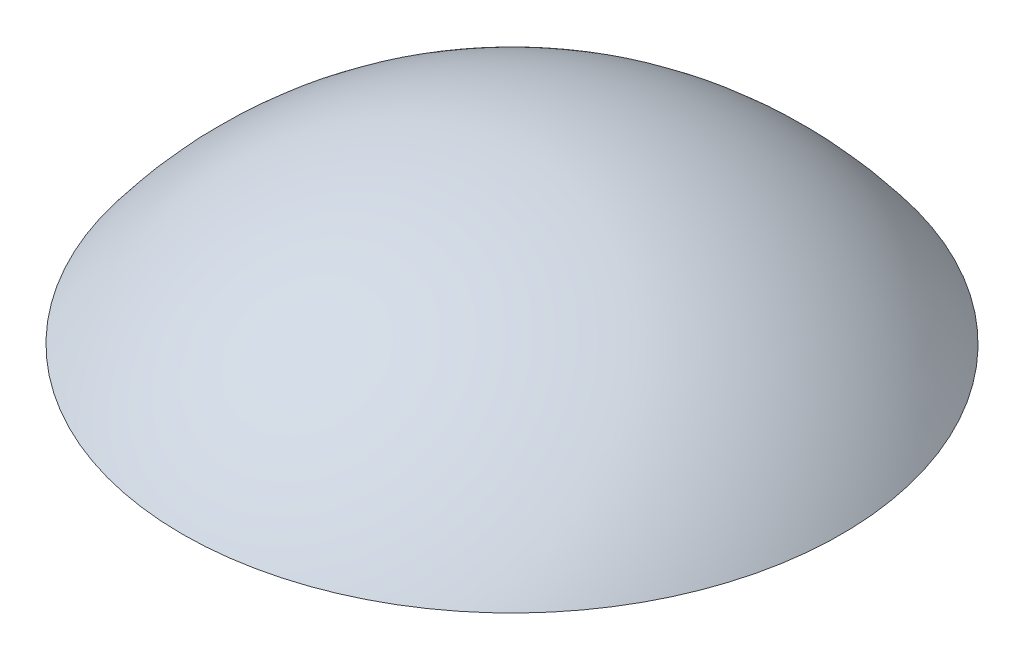
from build123d import *


with BuildPart() as part:
    # Sketch1 → Revolve1 (revolve)
    with BuildSketch(Plane(origin=(0, 0, 0), x_dir=(0, 0, -1), z_dir=(1, 0, 0))):
        with BuildLine():
            Line((25.4, 0), (0, 0))
            Line((0, 0), (0, 12.7))
            ThreePointArc((0, 12.7), (14.199031657, 9.348063314), (25.4, 0))
        make_face()
    revolve(axis=Axis((0, 12.7, 0), (0, -1, 0)))


solid = part.part
